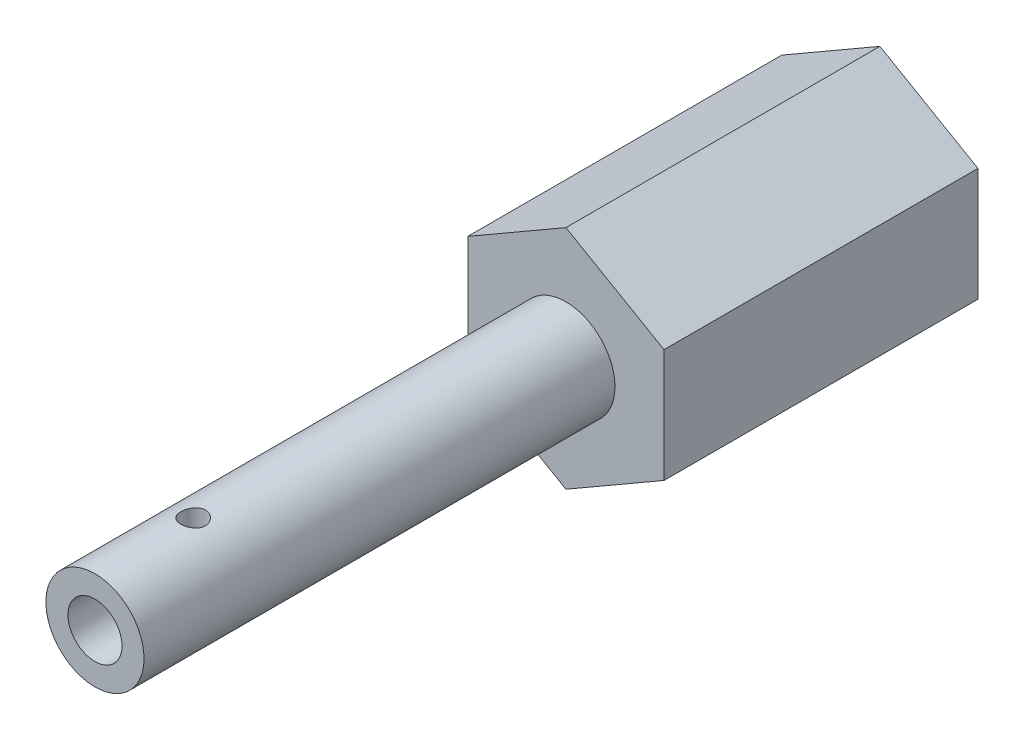
from build123d import *

# Parameters (mm, degrees)
BOSS_EXTRUDE1_DEPTH            = 20.32
SKETCH2_R                      = 3.175
BOSS_EXTRUDE2_DEPTH            = 30.48
F_3_5_3_5_DIAMETER_HOLE1_D     = 3.5
F_3_5_3_5_DIAMETER_HOLE1_DEPTH = 25.4
F_3_5_3_5_DIAMETER_HOLE1_TIP   = 1.051506083
F_1_16_0_0625_DIAMETER_HOLE1_D = 1.5875


with BuildPart() as part:
    # Sketch1 → Boss-Extrude1 (new body)
    with BuildSketch(Plane.XY):
        Polygon((0, 7.332348419), (-6.35, 3.666174209), (-6.35, -3.666174209), (0, -7.332348419), (6.35, -3.666174209), (6.35, 3.666174209), align=None)
    extrude(amount=BOSS_EXTRUDE1_DEPTH)

    # Sketch2 → Boss-Extrude2 (add)
    with BuildSketch(Plane.XY.offset(20.32)):
        Circle(SKETCH2_R)
    extrude(amount=BOSS_EXTRUDE2_DEPTH)

    # Ø3.5 (3.5) Diameter Hole1
    with Locations(Plane.XY.offset(50.8)):
        with Locations((0, 0)):
            Hole(F_3_5_3_5_DIAMETER_HOLE1_D / 2, depth=F_3_5_3_5_DIAMETER_HOLE1_DEPTH)
            with Locations((0, 0, -(F_3_5_3_5_DIAMETER_HOLE1_DEPTH + F_3_5_3_5_DIAMETER_HOLE1_TIP / 2))):  # 118° drill point
                Cone(0, F_3_5_3_5_DIAMETER_HOLE1_D / 2, F_3_5_3_5_DIAMETER_HOLE1_TIP, mode=Mode.SUBTRACT)

    # 1/16 (0.0625) Diameter Hole1 (through all)
    with Locations(Plane(origin=(0, 7.62, 0), x_dir=(1, 0, 0), z_dir=(0, 1, 0))):
        with Locations((0, -44.45)):
            Hole(F_1_16_0_0625_DIAMETER_HOLE1_D / 2)


solid = part.part
